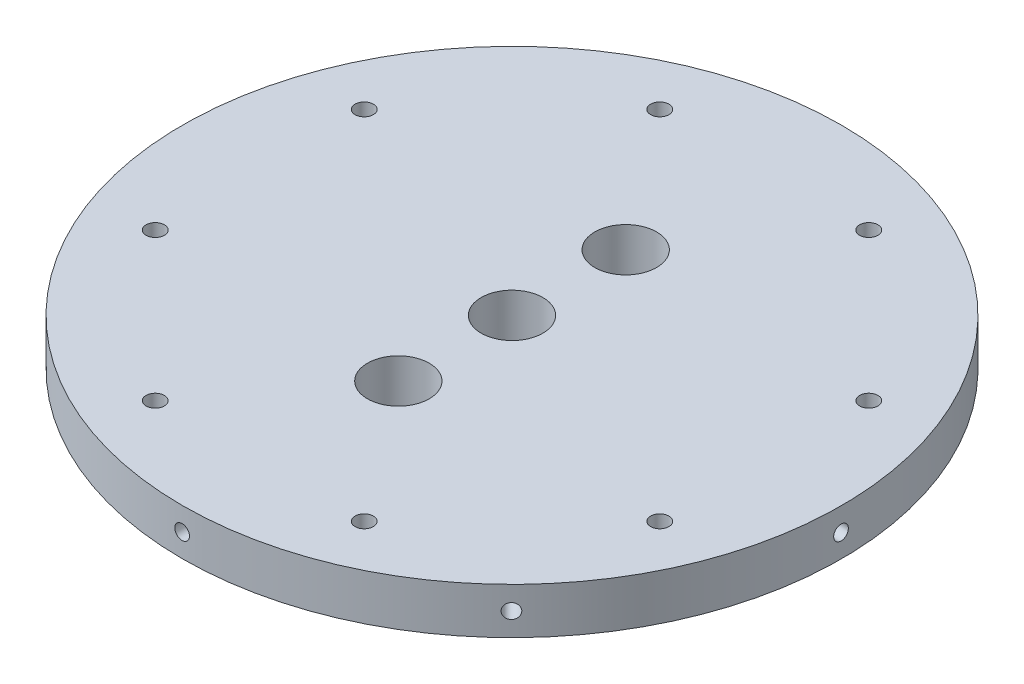
from build123d import *

# Parameters (mm, degrees)
SKETCH1_R                      = 50.8
BOSS_EXTRUDE1_DEPTH            = 7.112
SKETCH2_R                      = 4.7625
CUT_EXTRUDE1_DEPTH             = 8.112
F_4_40_TAPPED_HOLE1_AT_2_COUNT = 2
F_4_40_TAPPED_HOLE1_AT_2_PITCH = 18.336817374
CIRPATTERN7_COUNT              = 8
SKETCH11_R                     = 1.41224
CUT_EXTRUDE3_DEPTH             = 8.1120001
CIRPATTERN8_COUNT              = 8


with BuildPart() as part:
    # Sketch1 → Boss-Extrude1 (new body)
    with BuildSketch(Plane(origin=(0, 0, 0), x_dir=(1, 0, 0), z_dir=(0, 1, 0))):
        Circle(SKETCH1_R)
    extrude(amount=BOSS_EXTRUDE1_DEPTH)

    # Sketch2 → Cut-Extrude1 (cut, through all)
    with BuildSketch(Plane.XZ):
        Circle(SKETCH2_R)
        with Locations((0, -17.526)):
            Circle(SKETCH2_R)
        with Locations((0, 17.526)):
            Circle(SKETCH2_R)
    extrude(amount=-CUT_EXTRUDE1_DEPTH, mode=Mode.SUBTRACT)

    # Sketch8 → #4-40 Tapped Hole1 (revolve, cut)
    with BuildSketch(Plane(origin=(-0.062175227, 3.554407485, 50.799961951), x_dir=(0.999999251, 0, 0.001223922), z_dir=(0, 1, 0))):
        Polygon((0, 0), (0, 10.204152758), (1.1303, 9.525), (1.1303, 0), align=None)
    f_4_40_tapped_hole1 = revolve(axis=Axis((-0.062175227, 3.554407485, 50.799961951), (0.001223922, 0, -0.999999251)), mode=Mode.SUBTRACT)

    # #4-40 Tapped Hole1 at 2: #4-40 Tapped Hole1 ×2
    with Locations(*[Vector(0.92843035, 0.371504769, 0.001136327) * (i * F_4_40_TAPPED_HOLE1_AT_2_PITCH) for i in range(1, F_4_40_TAPPED_HOLE1_AT_2_COUNT)]):
        add(f_4_40_tapped_hole1, mode=Mode.SUBTRACT)

    # CirPattern7: #4-40 Tapped Hole1 ×8 about axis
    cirpattern7_axis = Axis((0, 7.112, 0), (0, 1, 0))
    for i in range(1, CIRPATTERN7_COUNT):
        add(f_4_40_tapped_hole1.rotate(cirpattern7_axis, i * 360 / CIRPATTERN7_COUNT), mode=Mode.SUBTRACT)

    # CirPattern7 copy 1 sketch → CirPattern7 copy 1 (revolve, cut)
    with BuildSketch(Plane(origin=(47.92987631, 10.366622592, 23.941586281), x_dir=(0.707971695, 0, -0.706240808), z_dir=(0, 1, 0))):
        Polygon((0, 0), (0, 10.204152758), (1.1303, 9.525), (1.1303, 0), align=None)
    revolve(axis=Axis((47.92987631, 10.366622592, 23.941586281), (-0.706240808, 0, -0.707971695)), mode=Mode.SUBTRACT)

    # CirPattern7 copy 2 sketch → CirPattern7 copy 2 (revolve, cut)
    with BuildSketch(Plane(origin=(50.820798572, 10.366622592, -16.962282549), x_dir=(0.001223922, 0, -0.999999251), z_dir=(0, 1, 0))):
        Polygon((0, 0), (0, 10.204152758), (1.1303, 9.525), (1.1303, 0), align=None)
    revolve(axis=Axis((50.820798572, 10.366622592, -16.962282549), (-0.999999251, 0, -0.001223922)), mode=Mode.SUBTRACT)

    # CirPattern7 copy 3 sketch → CirPattern7 copy 3 (revolve, cut)
    with BuildSketch(Plane(origin=(23.941586281, 10.366622592, -47.92987631), x_dir=(-0.706240808, 0, -0.707971695), z_dir=(0, 1, 0))):
        Polygon((0, 0), (0, 10.204152758), (1.1303, 9.525), (1.1303, 0), align=None)
    revolve(axis=Axis((23.941586281, 10.366622592, -47.92987631), (-0.707971695, 0, 0.706240808)), mode=Mode.SUBTRACT)

    # CirPattern7 copy 4 sketch → CirPattern7 copy 4 (revolve, cut)
    with BuildSketch(Plane(origin=(-16.962282549, 10.366622592, -50.820798572), x_dir=(-0.999999251, 0, -0.001223922), z_dir=(0, 1, 0))):
        Polygon((0, 0), (0, 10.204152758), (1.1303, 9.525), (1.1303, 0), align=None)
    revolve(axis=Axis((-16.962282549, 10.366622592, -50.820798572), (-0.001223922, 0, 0.999999251)), mode=Mode.SUBTRACT)

    # CirPattern7 copy 5 sketch → CirPattern7 copy 5 (revolve, cut)
    with BuildSketch(Plane(origin=(-47.92987631, 10.366622592, -23.941586281), x_dir=(-0.707971695, 0, 0.706240808), z_dir=(0, 1, 0))):
        Polygon((0, 0), (0, 10.204152758), (1.1303, 9.525), (1.1303, 0), align=None)
    revolve(axis=Axis((-47.92987631, 10.366622592, -23.941586281), (0.706240808, 0, 0.707971695)), mode=Mode.SUBTRACT)

    # CirPattern7 copy 6 sketch → CirPattern7 copy 6 (revolve, cut)
    with BuildSketch(Plane(origin=(-50.820798572, 10.366622592, 16.962282549), x_dir=(-0.001223922, 0, 0.999999251), z_dir=(0, 1, 0))):
        Polygon((0, 0), (0, 10.204152758), (1.1303, 9.525), (1.1303, 0), align=None)
    revolve(axis=Axis((-50.820798572, 10.366622592, 16.962282549), (0.999999251, 0, 0.001223922)), mode=Mode.SUBTRACT)

    # CirPattern7 copy 7 sketch → CirPattern7 copy 7 (revolve, cut)
    with BuildSketch(Plane(origin=(-23.941586281, 10.366622592, 47.92987631), x_dir=(0.706240808, 0, 0.707971695), z_dir=(0, 1, 0))):
        Polygon((0, 0), (0, 10.204152758), (1.1303, 9.525), (1.1303, 0), align=None)
    revolve(axis=Axis((-23.941586281, 10.366622592, 47.92987631), (0.707971695, 0, -0.706240808)), mode=Mode.SUBTRACT)

    # Sketch11 → Cut-Extrude3 (cut, through all)
    with BuildSketch(Plane(origin=(0, 7.112, 0), x_dir=(1, 0, 0), z_dir=(0, 1, 0))):
        with Locations((-38.892386202, 16.109753838)):
            Circle(SKETCH11_R)
    cut_extrude3 = extrude(amount=-CUT_EXTRUDE3_DEPTH, mode=Mode.SUBTRACT)

    # CirPattern8: Cut-Extrude3 ×8 about axis
    cirpattern8_axis = Axis((0, 0, 0), (0, 1, 0))
    for i in range(1, CIRPATTERN8_COUNT):
        add(cut_extrude3.rotate(cirpattern8_axis, i * 360 / CIRPATTERN8_COUNT), mode=Mode.SUBTRACT)


solid = part.part
